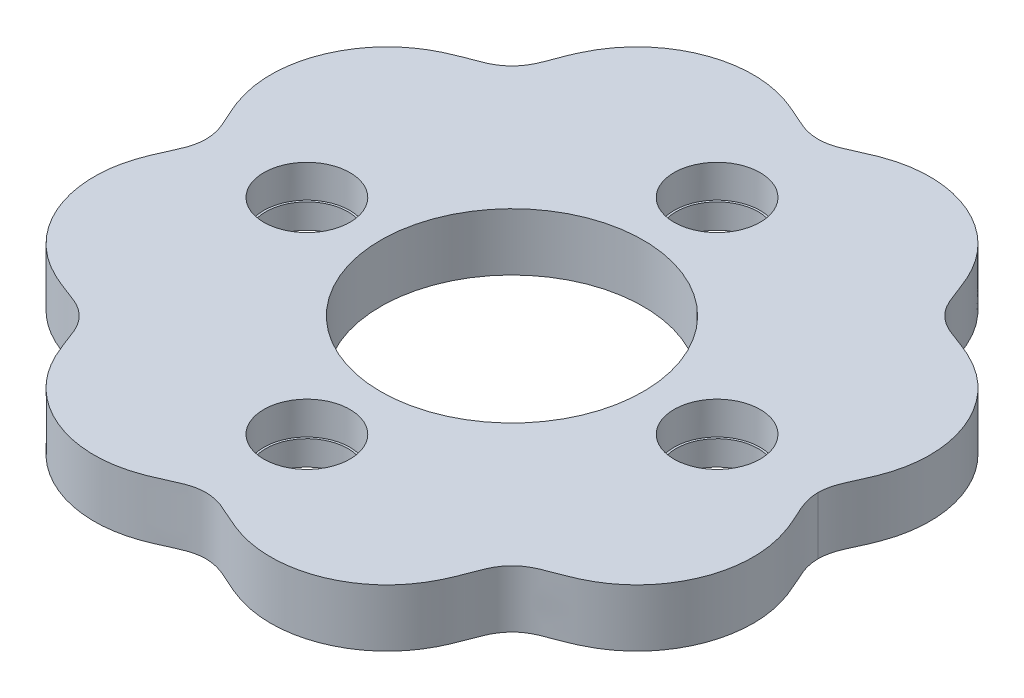
from build123d import *

# Parameters (mm, degrees)
BOSS_EXTRUDE1_DEPTH = 7
SKETCH3_R           = 16
SKETCH3_R_2         = 5.25
CUT_EXTRUDE1_DEPTH  = 7
CUT_EXTRUDE2_DEPTH  = 7
SKETCH5_R           = 5.25
SKETCH5_R_2         = 5
BOSS_EXTRUDE2_DEPTH = 3


with BuildPart() as part:
    # Sketch2 → Boss-Extrude1 (new body)
    with BuildSketch(Plane(origin=(0, 0, 0), x_dir=(1, 0, 0), z_dir=(0, 1, 0))):
        with BuildLine():
            add(Edge.make_bspline(
                [(37.500000178, 0), (37.500001348, -0.153650042), (37.516723117, -0.585734713), (37.60134551, -1.155885936), (37.799451038, -1.845132779), (38.055257689, -2.50061582), (38.284413658, -3.01884437), (38.547573645, -3.586057627), (38.834335204, -4.207231283), (39.213023964, -5.071386775), (39.642902809, -6.195484546), (40.034770345, -7.545626157), (40.309114863, -9.129071904), (40.402480997, -10.733442687), (40.292330227, -12.739242447), (39.800709206, -15.115411572), (38.875008006, -17.372282299), (37.550500891, -19.416826213), (36.201869244, -20.937061223), (34.991297456, -22.022332107), (33.664442598, -22.961820777), (32.418877976, -23.648429526), (31.307176029, -24.144813461), (30.415442254, -24.492540623), (29.760772524, -24.733252947), (29.159260868, -24.953726937), (28.615153012, -25.166050116), (27.968227921, -25.455751973), (27.242450172, -25.869161743), (26.486758972, -26.478530797), (25.788934233, -27.338578085), (25.333439826, -28.199550113), (25.02084924, -28.978917238), (24.756184284, -29.69717513), (24.520071708, -30.342148991), (24.176798097, -31.229963234), (23.685673389, -32.343953643), (23.006023391, -33.593318677), (22.074382722, -34.925670234), (20.99628636, -36.142619362), (19.483992231, -37.500137581), (17.436434568, -38.843473511), (15.165772212, -39.787003781), (12.765640508, -40.290729235), (10.727941267, -40.403684264), (9.098120231, -40.306732746), (7.490297544, -40.023060283), (6.12050869, -39.618509318), (4.980859334, -39.175936442), (3.981084292, -38.733166074), (3.107747272, -38.323212218), (2.16284156, -37.896233325), (1.102684883, -37.568652762), (-4e-09, -37.451718585), (-1.102684874, -37.568652759), (-2.162841573, -37.896233332), (-3.107747248, -38.323212203), (-3.981084328, -38.733166098), (-4.980859269, -39.175936398), (-6.120508811, -39.6185094), (-7.490297349, -40.023060149), (-9.098120503, -40.306732933), (-10.727940878, -40.403683996), (-12.765641194, -40.290729708), (-15.165770912, -39.787002885), (-17.436436591, -38.843474905), (-19.48398961, -37.500135775), (-20.996290415, -36.142622155), (-22.074374394, -34.925664496), (-23.006039129, -33.59332952), (-23.685647307, -32.343935674), (-24.176838549, -31.229991103), (-24.570729586, -30.210893235), (-24.899588849, -29.300399238), (-25.267416458, -28.324512461), (-25.788900803, -27.338555053), (-26.486780724, -26.478545782), (-27.242436428, -25.869152274), (-27.968236735, -25.455758045), (-28.615147496, -25.166046316), (-29.159264206, -24.953729236), (-29.760770668, -24.733251668), (-30.415443148, -24.492541238), (-31.307175489, -24.144813089), (-32.41887831, -23.648429756), (-33.6644424, -22.96182064), (-34.99129756, -22.022332179), (-36.201869193, -20.937061188), (-37.550500924, -19.416826235), (-38.875007981, -17.372282282), (-39.800709222, -15.115411584), (-40.292330218, -12.739242441), (-40.402481002, -10.733442691), (-40.309114859, -9.129071901), (-40.034770347, -7.545626159), (-39.642902807, -6.195484545), (-39.213023965, -5.071386776), (-38.834335204, -4.207231283), (-38.547573646, -3.586057627), (-38.284413658, -3.01884437), (-38.055257689, -2.50061582), (-37.799451038, -1.845132779), (-37.60134551, -1.155885936), (-37.516723117, -0.585734713), (-37.500001348, -0.153650042), (-37.500000178, 0)],
                knots=[0.119900748, 0.119900748, 0.119900748, 0.119900748, 0.119900748, 0.123359436, 0.129627259, 0.132815238, 0.136003217, 0.139191195, 0.142379174, 0.14689104, 0.151402906, 0.160426638, 0.169450869, 0.1784751, 0.187499512, 0.196523925, 0.214572937, 0.232831382, 0.241960244, 0.251089107, 0.260218415, 0.269347723, 0.278476117, 0.283040314, 0.287604511, 0.290890352, 0.294176194, 0.297462035, 0.300747877, 0.306837966, 0.312927068, 0.319161334, 0.325493528, 0.328659626, 0.331825723, 0.336390118, 0.340954513, 0.350083302, 0.35921236, 0.368341418, 0.377470301, 0.386599184, 0.404857643, 0.423193135, 0.432360527, 0.441527919, 0.450695565, 0.459863212, 0.469030281, 0.473613816, 0.47819735, 0.484472892, 0.490748434, 0.496943117, 0.503056883, 0.509251566, 0.515527108, 0.52180265, 0.526386184, 0.530969719, 0.540136788, 0.549304435, 0.558472081, 0.567639473, 0.576806865, 0.595142357, 0.613400816, 0.622529699, 0.631658582, 0.64078764, 0.649916698, 0.659045487, 0.663609882, 0.668174277, 0.674506472, 0.680838666, 0.687072932, 0.693162034, 0.699252123, 0.702537965, 0.705823806, 0.709109648, 0.712395489, 0.716959686, 0.721523883, 0.730652277, 0.739781585, 0.748910893, 0.758039756, 0.767168618, 0.785427063, 0.803476075, 0.812500488, 0.8215249, 0.830549131, 0.839573362, 0.848597094, 0.85310896, 0.857620826, 0.860808805, 0.863996783, 0.867184762, 0.870372741, 0.876640564, 0.880099252, 0.880099252, 0.880099252, 0.880099252, 0.880099252], degree=4))
            add(Edge.make_bspline(
                [(37.500000178, 0), (37.500001348, 0.153650042), (37.516723117, 0.585734713), (37.60134551, 1.155885936), (37.799451038, 1.845132779), (38.055257689, 2.50061582), (38.284413658, 3.018844371), (38.547573645, 3.586057627), (38.834335204, 4.207231284), (39.213023964, 5.071386775), (39.642902809, 6.195484546), (40.034770345, 7.545626157), (40.309114863, 9.129071904), (40.402480997, 10.733442688), (40.292330227, 12.739242447), (39.800709205, 15.115411572), (38.875008006, 17.3722823), (37.550500891, 19.416826213), (36.201869244, 20.937061223), (34.991297456, 22.022332107), (33.664442598, 22.961820777), (32.418877976, 23.648429526), (31.307176029, 24.144813461), (30.415442254, 24.492540623), (29.760772524, 24.733252947), (29.159260868, 24.953726937), (28.615153012, 25.166050117), (27.968227921, 25.455751974), (27.242450172, 25.869161744), (26.486758972, 26.478530797), (25.788934233, 27.338578085), (25.333439826, 28.199550113), (25.02084924, 28.978917238), (24.756184284, 29.69717513), (24.520071708, 30.342148991), (24.176798097, 31.229963234), (23.685673389, 32.343953643), (23.006023391, 33.593318677), (22.074382722, 34.925670234), (20.99628636, 36.142619362), (19.483992231, 37.500137582), (17.436434568, 38.843473511), (15.165772212, 39.787003781), (12.765640508, 40.290729235), (10.727941267, 40.403684265), (9.098120231, 40.306732746), (7.490297544, 40.023060283), (6.12050869, 39.618509318), (4.980859334, 39.175936443), (3.981084292, 38.733166074), (3.107747271, 38.323212218), (2.162841559, 37.896233325), (1.102684882, 37.568652762), (-4e-09, 37.451718586), (-1.102684874, 37.568652759), (-2.162841573, 37.896233332), (-3.107747248, 38.323212203), (-3.981084328, 38.733166098), (-4.980859269, 39.175936399), (-6.120508811, 39.6185094), (-7.490297349, 40.023060149), (-9.098120503, 40.306732933), (-10.727940878, 40.403683996), (-12.765641194, 40.290729708), (-15.165770912, 39.787002885), (-17.436436591, 38.843474905), (-19.48398961, 37.500135776), (-20.996290415, 36.142622155), (-22.074374394, 34.925664496), (-23.006039129, 33.59332952), (-23.685647307, 32.343935674), (-24.176838549, 31.229991103), (-24.570729586, 30.210893235), (-24.899588849, 29.300399238), (-25.267416458, 28.324512461), (-25.788900803, 27.338555053), (-26.486780724, 26.478545782), (-27.242436428, 25.869152274), (-27.968236735, 25.455758045), (-28.615147496, 25.166046316), (-29.159264206, 24.953729236), (-29.760770668, 24.733251668), (-30.415443148, 24.492541238), (-31.307175489, 24.144813089), (-32.418878311, 23.648429756), (-33.6644424, 22.96182064), (-34.99129756, 22.022332179), (-36.201869193, 20.937061188), (-37.550500924, 19.416826235), (-38.875007981, 17.372282282), (-39.800709222, 15.115411584), (-40.292330218, 12.739242441), (-40.402481002, 10.733442691), (-40.309114859, 9.129071901), (-40.034770347, 7.545626159), (-39.642902807, 6.195484545), (-39.213023965, 5.071386776), (-38.834335204, 4.207231283), (-38.547573646, 3.586057627), (-38.284413658, 3.01884437), (-38.055257689, 2.50061582), (-37.799451038, 1.845132779), (-37.60134551, 1.155885936), (-37.516723117, 0.585734713), (-37.500001348, 0.153650042), (-37.500000178, 0)],
                knots=[0.119900748, 0.119900748, 0.119900748, 0.119900748, 0.119900748, 0.123359436, 0.129627259, 0.132815238, 0.136003217, 0.139191195, 0.142379174, 0.14689104, 0.151402906, 0.160426638, 0.169450869, 0.1784751, 0.187499512, 0.196523925, 0.214572937, 0.232831382, 0.241960244, 0.251089107, 0.260218415, 0.269347723, 0.278476117, 0.283040314, 0.287604511, 0.290890352, 0.294176194, 0.297462035, 0.300747877, 0.306837966, 0.312927068, 0.319161334, 0.325493528, 0.328659626, 0.331825723, 0.336390118, 0.340954513, 0.350083302, 0.35921236, 0.368341418, 0.377470301, 0.386599184, 0.404857643, 0.423193135, 0.432360527, 0.441527919, 0.450695565, 0.459863212, 0.469030281, 0.473613816, 0.47819735, 0.484472892, 0.490748434, 0.496943117, 0.503056883, 0.509251566, 0.515527108, 0.52180265, 0.526386184, 0.530969719, 0.540136788, 0.549304435, 0.558472081, 0.567639473, 0.576806865, 0.595142357, 0.613400816, 0.622529699, 0.631658582, 0.64078764, 0.649916698, 0.659045487, 0.663609882, 0.668174277, 0.674506472, 0.680838666, 0.687072932, 0.693162034, 0.699252123, 0.702537965, 0.705823806, 0.709109648, 0.712395489, 0.716959686, 0.721523883, 0.730652277, 0.739781585, 0.748910893, 0.758039756, 0.767168618, 0.785427063, 0.803476075, 0.812500488, 0.8215249, 0.830549131, 0.839573362, 0.848597094, 0.85310896, 0.857620826, 0.860808805, 0.863996783, 0.867184762, 0.870372741, 0.876640564, 0.880099252, 0.880099252, 0.880099252, 0.880099252, 0.880099252], degree=4))
        make_face()
    extrude(amount=BOSS_EXTRUDE1_DEPTH)

    # Sketch3 → Cut-Extrude1 (cut)
    with BuildSketch(Plane(origin=(0, 7, 0), x_dir=(1, 0, 0), z_dir=(0, 1, 0))):
        with Locations(Location((0, 0, 0), (0, 0, 270))):
            Circle(SKETCH3_R)
        with Locations(Location((25, 0, 0), (0, 0, 270))):
            Circle(SKETCH3_R_2)
        with Locations(Location((0, -25, 0), (0, 0, 270))):
            Circle(SKETCH3_R_2)
        with Locations(Location((-25, 0, 0), (0, 0, 270))):
            Circle(SKETCH3_R_2)
        with Locations(Location((0, 25, 0), (0, 0, 270))):
            Circle(SKETCH3_R_2)
    extrude(amount=-CUT_EXTRUDE1_DEPTH, mode=Mode.SUBTRACT)

    # Sketch4 → Cut-Extrude2 (cut)
    with BuildSketch(Plane.XZ):
        with BuildLine():
            add(Edge.make_bspline(
                [(37.500000178, 0), (37.500001348, 0.153650042), (37.516723117, 0.585734713), (37.60134551, 1.155885936), (37.799451038, 1.845132779), (38.055257689, 2.50061582), (38.284413658, 3.01884437), (38.547573645, 3.586057627), (38.834335204, 4.207231283), (39.213023964, 5.071386775), (39.642902809, 6.195484546), (40.034770345, 7.545626157), (40.309114863, 9.129071904), (40.402480997, 10.733442687), (40.292330227, 12.739242447), (39.800709206, 15.115411572), (38.875008006, 17.372282299), (37.550500891, 19.416826213), (36.201869244, 20.937061223), (34.991297456, 22.022332107), (33.664442598, 22.961820777), (32.418877976, 23.648429526), (31.307176029, 24.144813461), (30.415442254, 24.492540623), (29.760772524, 24.733252947), (29.159260868, 24.953726937), (28.615153012, 25.166050116), (27.968227921, 25.455751973), (27.242450172, 25.869161743), (26.486758972, 26.478530797), (25.788934233, 27.338578085), (25.333439826, 28.199550113), (25.02084924, 28.978917238), (24.756184284, 29.69717513), (24.520071708, 30.342148991), (24.176798097, 31.229963234), (23.685673389, 32.343953643), (23.006023391, 33.593318677), (22.074382722, 34.925670234), (20.99628636, 36.142619362), (19.483992231, 37.500137581), (17.436434568, 38.843473511), (15.165772212, 39.787003781), (12.765640508, 40.290729235), (10.727941267, 40.403684264), (9.098120231, 40.306732746), (7.490297544, 40.023060283), (6.12050869, 39.618509318), (4.980859334, 39.175936442), (3.981084292, 38.733166074), (3.107747272, 38.323212218), (2.16284156, 37.896233325), (1.102684883, 37.568652762), (-4e-09, 37.451718585), (-1.102684874, 37.568652759), (-2.162841573, 37.896233332), (-3.107747248, 38.323212203), (-3.981084328, 38.733166098), (-4.980859269, 39.175936398), (-6.120508811, 39.6185094), (-7.490297349, 40.023060149), (-9.098120503, 40.306732933), (-10.727940878, 40.403683996), (-12.765641194, 40.290729708), (-15.165770912, 39.787002885), (-17.436436591, 38.843474905), (-19.48398961, 37.500135775), (-20.996290415, 36.142622155), (-22.074374394, 34.925664496), (-23.006039129, 33.59332952), (-23.685647307, 32.343935674), (-24.176838549, 31.229991103), (-24.570729586, 30.210893235), (-24.899588849, 29.300399238), (-25.267416458, 28.324512461), (-25.788900803, 27.338555053), (-26.486780724, 26.478545782), (-27.242436428, 25.869152274), (-27.968236735, 25.455758045), (-28.615147496, 25.166046316), (-29.159264206, 24.953729236), (-29.760770668, 24.733251668), (-30.415443148, 24.492541238), (-31.307175489, 24.144813089), (-32.41887831, 23.648429756), (-33.6644424, 22.96182064), (-34.99129756, 22.022332179), (-36.201869193, 20.937061188), (-37.550500924, 19.416826235), (-38.875007981, 17.372282282), (-39.800709222, 15.115411584), (-40.292330218, 12.739242441), (-40.402481002, 10.733442691), (-40.309114859, 9.129071901), (-40.034770347, 7.545626159), (-39.642902807, 6.195484545), (-39.213023965, 5.071386776), (-38.834335204, 4.207231283), (-38.547573646, 3.586057627), (-38.284413658, 3.01884437), (-38.055257689, 2.50061582), (-37.799451038, 1.845132779), (-37.60134551, 1.155885936), (-37.516723117, 0.585734713), (-37.500001348, 0.153650042), (-37.500000178, 0)],
                knots=[0.119900748, 0.119900748, 0.119900748, 0.119900748, 0.119900748, 0.123359436, 0.129627259, 0.132815238, 0.136003217, 0.139191195, 0.142379174, 0.14689104, 0.151402906, 0.160426638, 0.169450869, 0.1784751, 0.187499512, 0.196523925, 0.214572937, 0.232831382, 0.241960244, 0.251089107, 0.260218415, 0.269347723, 0.278476117, 0.283040314, 0.287604511, 0.290890352, 0.294176194, 0.297462035, 0.300747877, 0.306837966, 0.312927068, 0.319161334, 0.325493528, 0.328659626, 0.331825723, 0.336390118, 0.340954513, 0.350083302, 0.35921236, 0.368341418, 0.377470301, 0.386599184, 0.404857643, 0.423193135, 0.432360527, 0.441527919, 0.450695565, 0.459863212, 0.469030281, 0.473613816, 0.47819735, 0.484472892, 0.490748434, 0.496943117, 0.503056883, 0.509251566, 0.515527108, 0.52180265, 0.526386184, 0.530969719, 0.540136788, 0.549304435, 0.558472081, 0.567639473, 0.576806865, 0.595142357, 0.613400816, 0.622529699, 0.631658582, 0.64078764, 0.649916698, 0.659045487, 0.663609882, 0.668174277, 0.674506472, 0.680838666, 0.687072932, 0.693162034, 0.699252123, 0.702537965, 0.705823806, 0.709109648, 0.712395489, 0.716959686, 0.721523883, 0.730652277, 0.739781585, 0.748910893, 0.758039756, 0.767168618, 0.785427063, 0.803476075, 0.812500488, 0.8215249, 0.830549131, 0.839573362, 0.848597094, 0.85310896, 0.857620826, 0.860808805, 0.863996783, 0.867184762, 0.870372741, 0.876640564, 0.880099252, 0.880099252, 0.880099252, 0.880099252, 0.880099252], degree=4))
            add(Edge.make_bspline(
                [(-37.500000178, 0), (-37.500001348, -0.153650042), (-37.516723117, -0.585734713), (-37.60134551, -1.155885936), (-37.799451038, -1.845132779), (-38.055257689, -2.50061582), (-38.284413658, -3.01884437), (-38.547573646, -3.586057627), (-38.834335204, -4.207231283), (-39.213023965, -5.071386776), (-39.642902807, -6.195484545), (-40.034770347, -7.545626159), (-40.309114859, -9.129071901), (-40.402481002, -10.733442691), (-40.292330218, -12.739242441), (-39.800709222, -15.115411584), (-38.875007981, -17.372282282), (-37.550500924, -19.416826235), (-36.201869193, -20.937061188), (-34.99129756, -22.022332179), (-33.6644424, -22.96182064), (-32.418878311, -23.648429756), (-31.307175489, -24.144813089), (-30.415443148, -24.492541238), (-29.760770668, -24.733251668), (-29.159264206, -24.953729236), (-28.615147496, -25.166046316), (-27.968236735, -25.455758045), (-27.242436428, -25.869152274), (-26.486780724, -26.478545782), (-25.788900803, -27.338555053), (-25.267416458, -28.324512461), (-24.899588849, -29.300399238), (-24.570729586, -30.210893235), (-24.176838549, -31.229991103), (-23.685647307, -32.343935674), (-23.006039129, -33.59332952), (-22.074374394, -34.925664496), (-20.996290415, -36.142622155), (-19.48398961, -37.500135776), (-17.436436591, -38.843474905), (-15.165770912, -39.787002885), (-12.765641194, -40.290729708), (-10.727940878, -40.403683996), (-9.098120503, -40.306732933), (-7.490297349, -40.023060149), (-6.120508811, -39.6185094), (-4.980859269, -39.175936399), (-3.981084328, -38.733166098), (-3.107747248, -38.323212203), (-2.162841573, -37.896233332), (-1.102684874, -37.568652759), (-4e-09, -37.451718586), (1.102684882, -37.568652762), (2.162841559, -37.896233325), (3.107747271, -38.323212218), (3.981084292, -38.733166074), (4.980859334, -39.175936443), (6.12050869, -39.618509318), (7.490297544, -40.023060283), (9.098120231, -40.306732746), (10.727941267, -40.403684265), (12.765640508, -40.290729235), (15.165772212, -39.787003781), (17.436434568, -38.843473511), (19.483992231, -37.500137582), (20.99628636, -36.142619362), (22.074382722, -34.925670234), (23.006023391, -33.593318677), (23.685673389, -32.343953643), (24.176798097, -31.229963234), (24.520071708, -30.342148991), (24.756184284, -29.69717513), (25.02084924, -28.978917238), (25.333439826, -28.199550113), (25.788934233, -27.338578085), (26.486758972, -26.478530797), (27.242450172, -25.869161744), (27.968227921, -25.455751974), (28.615153012, -25.166050117), (29.159260868, -24.953726937), (29.760772524, -24.733252947), (30.415442254, -24.492540623), (31.307176029, -24.144813461), (32.418877976, -23.648429526), (33.664442598, -22.961820777), (34.991297456, -22.022332107), (36.201869244, -20.937061223), (37.550500891, -19.416826213), (38.875008006, -17.3722823), (39.800709205, -15.115411572), (40.292330227, -12.739242447), (40.402480997, -10.733442688), (40.309114863, -9.129071904), (40.034770345, -7.545626157), (39.642902809, -6.195484546), (39.213023964, -5.071386775), (38.834335204, -4.207231284), (38.547573645, -3.586057627), (38.284413658, -3.018844371), (38.055257689, -2.50061582), (37.799451038, -1.845132779), (37.60134551, -1.155885936), (37.516723117, -0.585734713), (37.500001348, -0.153650042), (37.500000178, 0)],
                knots=[0.119900748, 0.119900748, 0.119900748, 0.119900748, 0.119900748, 0.123359436, 0.129627259, 0.132815238, 0.136003217, 0.139191195, 0.142379174, 0.14689104, 0.151402906, 0.160426638, 0.169450869, 0.1784751, 0.187499512, 0.196523925, 0.214572937, 0.232831382, 0.241960244, 0.251089107, 0.260218415, 0.269347723, 0.278476117, 0.283040314, 0.287604511, 0.290890352, 0.294176194, 0.297462035, 0.300747877, 0.306837966, 0.312927068, 0.319161334, 0.325493528, 0.331825723, 0.336390118, 0.340954513, 0.350083302, 0.35921236, 0.368341418, 0.377470301, 0.386599184, 0.404857643, 0.423193135, 0.432360527, 0.441527919, 0.450695565, 0.459863212, 0.469030281, 0.473613816, 0.47819735, 0.484472892, 0.490748434, 0.496943117, 0.503056883, 0.509251566, 0.515527108, 0.52180265, 0.526386184, 0.530969719, 0.540136788, 0.549304435, 0.558472081, 0.567639473, 0.576806865, 0.595142357, 0.613400816, 0.622529699, 0.631658582, 0.64078764, 0.649916698, 0.659045487, 0.663609882, 0.668174277, 0.671340374, 0.674506472, 0.680838666, 0.687072932, 0.693162034, 0.699252123, 0.702537965, 0.705823806, 0.709109648, 0.712395489, 0.716959686, 0.721523883, 0.730652277, 0.739781585, 0.748910893, 0.758039756, 0.767168618, 0.785427063, 0.803476075, 0.812500488, 0.8215249, 0.830549131, 0.839573362, 0.848597094, 0.85310896, 0.857620826, 0.860808805, 0.863996783, 0.867184762, 0.870372741, 0.876640564, 0.880099252, 0.880099252, 0.880099252, 0.880099252, 0.880099252], degree=4))
        make_face()
        with BuildLine():
            add(Edge.make_bspline(
                [(-37.300000178, -1.524e-06), (-37.300005335, -0.676867371), (-37.427636497, -1.325473476), (-37.853250651, -2.584965326), (-38.147131523, -3.195245044), (-38.710737195, -4.418667543), (-38.982798601, -5.033561115), (-39.450771862, -6.288224734), (-39.648035819, -6.927553077), (-39.875673706, -7.908844077), (-39.940344955, -8.239602513), (-40.046090854, -8.908827903), (-40.087286369, -9.248679407), (-40.172949866, -10.27022305), (-40.179625206, -10.947626333), (-40.096430658, -12.295492001), (-40.006581856, -12.965955902), (-39.798317767, -13.966368295), (-39.716248424, -14.299914705), (-39.529875703, -14.955124894), (-39.425421525, -15.277863119), (-39.07900274, -16.231799922), (-38.804163449, -16.848799053), (-38.166153555, -18.044644678), (-37.799492988, -18.627625556), (-36.995130035, -19.722329216), (-36.55702023, -20.236493497), (-35.609382413, -21.198851965), (-35.098848237, -21.647731332), (-34.006848553, -22.473314445), (-33.436641819, -22.841333302), (-32.252551038, -23.49658613), (-31.638105387, -23.782781365), (-30.693579545, -24.169797582), (-30.374923098, -24.29196642), (-29.735334328, -24.530156066), (-29.414121244, -24.64587707), (-28.776119551, -24.887840957), (-28.459558035, -25.014623888), (-27.841899581, -25.30496618), (-27.538474652, -25.470402701), (-26.968530323, -25.84818003), (-26.70266287, -26.059307537), (-26.212204012, -26.529609939), (-25.985689891, -26.791762949), (-25.586463853, -27.347680771), (-25.41329678, -27.640928729), (-25.106118272, -28.250061479), (-24.972145407, -28.566214123), (-24.721951409, -29.207052359), (-24.604673392, -29.531396076), (-24.365978823, -30.178006246), (-24.244860769, -30.500422525), (-23.861965565, -31.457863081), (-23.579994139, -32.082751199), (-22.93073246, -33.289703159), (-22.564564445, -33.872330289), (-21.944749407, -34.710853127), (-21.725410999, -34.985571353), (-21.270313026, -35.513530833), (-21.034058454, -35.767647044), (-20.299828428, -36.501142055), (-19.77651621, -36.951814008), (-18.662658422, -37.776981752), (-18.067184766, -38.153631121), (-16.84205779, -38.808251323), (-16.210381542, -39.088693428), (-15.234619198, -39.440087375), (-14.904636476, -39.545623277), (-14.235030876, -39.733055651), (-13.893995034, -39.815213549), (-12.183094407, -40.161008791), (-10.804309777, -40.234150035), (-9.068024089, -40.066663686), (-8.719971551, -40.019815553), (-8.033988167, -39.901414802), (-7.694604804, -39.829735338), (-6.686761662, -39.579051281), (-6.02890771, -39.363367369), (-4.734913886, -38.856903314), (-4.09967909, -38.563862442), (-2.831226885, -37.978648162), (-2.195461735, -37.68983752), (-1.177345947, -37.415650241), (-0.830881373, -37.351821484), (-0.138817065, -37.29091559), (0.20907518, -37.292911809), (0.908697102, -37.363847996), (1.254123511, -37.432795894), (1.923534855, -37.620991628), (2.250175655, -37.740536869), (2.894567623, -38.007677129), (3.212569296, -38.154445485), (3.848679122, -38.448235746), (4.166662192, -38.595380732), (5.126011798, -39.018034516), (5.77299927, -39.273995175), (7.093462946, -39.693795626), (7.766556663, -39.858965602), (8.79794485, -40.031088074), (9.145338463, -40.075950894), (9.84763557, -40.139559133), (10.204439892, -40.158296893), (11.981061205, -40.183352107), (13.374101934, -39.99116426), (15.0807472, -39.4906324), (15.418995639, -39.377488677), (16.081101817, -39.128399482), (16.406210156, -38.992100462), (17.363980082, -38.548492104), (17.97919541, -38.206686663), (18.866236672, -37.623228073), (19.157096225, -37.415961043), (19.7199732, -36.981810571), (19.991631279, -36.755377595), (20.777834873, -36.048551371), (21.26373655, -35.540752153), (21.934837883, -34.723797907), (22.148877277, -34.442236285), (22.557321054, -33.860326574), (22.751308058, -33.560329192), (23.296633068, -32.645197526), (23.613079431, -32.01037547), (24.035024821, -31.030456758), (24.167085908, -30.699362692), (24.42071489, -30.03357086), (24.542165455, -29.698502186), (24.789943229, -29.030340214), (24.916288451, -28.697254212), (25.203031469, -28.04487583), (25.365328746, -27.723501519), (25.738863592, -27.118626541), (25.949588891, -26.83484909), (26.425345949, -26.30959178), (26.693427061, -26.066305249), (27.262376931, -25.640526196), (27.56458752, -25.45587752), (28.196201984, -25.129880607), (28.525768024, -24.988616885), (29.195057198, -24.725991917), (29.534624796, -24.603555748), (30.211020774, -24.35374453), (30.54805671, -24.22674371), (31.547163494, -23.824103094), (32.196759504, -23.525970845), (33.44512828, -22.83807073), (34.04463883, -22.449633109), (34.902881218, -21.793010366), (35.18215621, -21.561865079), (35.726440643, -21.073853349), (35.992909512, -20.815365155), (36.754934237, -20.015059637), (37.215569576, -19.447621742), (38.045919188, -18.247692555), (38.41581225, -17.614905719), (39.060809726, -16.283216984), (39.327825486, -15.601135481), (39.755290796, -14.205785793), (39.915743077, -13.492518407), (40.073287437, -12.398288082), (40.111713427, -12.029358579), (40.159120983, -11.296377239), (40.168380307, -10.930685523), (40.153413888, -9.835974665), (40.086539323, -9.109314524), (39.899940664, -8.024097027), (39.822944519, -7.661850311), (39.641972096, -6.946076066), (39.53821078, -6.592991809), (39.19106012, -5.546715434), (38.9097543, -4.867241305), (38.454863731, -3.859944684), (38.297872988, -3.526119045), (37.992404669, -2.855385887), (37.844569648, -2.518245277), (37.590630842, -1.828852716), (37.484865024, -1.476478384), (37.339064604, -0.747927725), (37.300003029, -0.374141758), (37.300000178, -1.524e-06)],
                knots=[0, 0, 0, 0, 0.015625, 0.015625, 0.03125, 0.03125, 0.046875, 0.046875, 0.0625, 0.0625, 0.0703125, 0.0703125, 0.078125, 0.078125, 0.09375, 0.09375, 0.109375, 0.109375, 0.1171875, 0.1171875, 0.125, 0.125, 0.140625, 0.140625, 0.15625, 0.15625, 0.171875, 0.171875, 0.1875, 0.1875, 0.203125, 0.203125, 0.21875, 0.21875, 0.2265625, 0.2265625, 0.234375, 0.234375, 0.2421875, 0.2421875, 0.25, 0.25, 0.2578125, 0.2578125, 0.265625, 0.265625, 0.2734375, 0.2734375, 0.28125, 0.28125, 0.2890625, 0.2890625, 0.296875, 0.296875, 0.3125, 0.3125, 0.328125, 0.328125, 0.3359375, 0.3359375, 0.34375, 0.34375, 0.359375, 0.359375, 0.375, 0.375, 0.390625, 0.390625, 0.3984375, 0.3984375, 0.40625, 0.40625, 0.4375, 0.4375, 0.4453125, 0.4453125, 0.453125, 0.453125, 0.46875, 0.46875, 0.484375, 0.484375, 0.5, 0.5, 0.5078125, 0.5078125, 0.515625, 0.515625, 0.5234375, 0.5234375, 0.53125, 0.53125, 0.5390625, 0.5390625, 0.546875, 0.546875, 0.5625, 0.5625, 0.578125, 0.578125, 0.5859375, 0.5859375, 0.59375, 0.59375, 0.625, 0.625, 0.6328125, 0.6328125, 0.640625, 0.640625, 0.65625, 0.65625, 0.6640625, 0.6640625, 0.671875, 0.671875, 0.6875, 0.6875, 0.6953125, 0.6953125, 0.703125, 0.703125, 0.71875, 0.71875, 0.7265625, 0.7265625, 0.734375, 0.734375, 0.7421875, 0.7421875, 0.75, 0.75, 0.7578125, 0.7578125, 0.765625, 0.765625, 0.7734375, 0.7734375, 0.78125, 0.78125, 0.7890625, 0.7890625, 0.796875, 0.796875, 0.8125, 0.8125, 0.828125, 0.828125, 0.8359375, 0.8359375, 0.84375, 0.84375, 0.859375, 0.859375, 0.875, 0.875, 0.890625, 0.890625, 0.90625, 0.90625, 0.9140625, 0.9140625, 0.921875, 0.921875, 0.9375, 0.9375, 0.9453125, 0.9453125, 0.953125, 0.953125, 0.96875, 0.96875, 0.9765625, 0.9765625, 0.984375, 0.984375, 0.9921875, 0.9921875, 1, 1, 1, 1], degree=3))
            add(Edge.make_bspline(
                [(37.300000178, -1.524e-06), (37.300005208, 0.660144226), (37.421411779, 1.295517379), (37.831734078, 2.532082599), (38.116935876, 3.130913102), (38.66996567, 4.329106329), (38.939096345, 4.930571557), (39.405964802, 6.156402501), (39.605047777, 6.780336723), (39.916633728, 8.055977178), (40.029822796, 8.707463335), (40.129263615, 9.707256218), (40.150476293, 10.043512099), (40.168603216, 10.710754532), (40.16569842, 11.043295862), (40.121853762, 12.037750073), (40.04596153, 12.696509229), (39.800930827, 14.005614003), (39.629929243, 14.660025043), (39.203319809, 15.922840902), (38.947607438, 16.534995728), (38.352443795, 17.721287864), (38.01164261, 18.297386991), (36.865619793, 19.953006208), (35.965077358, 20.925749976), (34.668200294, 21.977408574), (34.399137664, 22.180045191), (33.849124311, 22.564175613), (33.568194294, 22.745768199), (32.708435952, 23.26054556), (32.112158136, 23.562879166), (30.883355545, 24.103460776), (30.253463108, 24.33873727), (28.992284812, 24.802673436), (28.359269177, 25.033693876), (27.173041908, 25.672514094), (26.640421314, 26.071830768), (25.732243211, 27.075117404), (25.3881266, 27.646349548), (24.970450113, 28.565526018), (24.847078992, 28.880994442), (24.608670909, 29.516260023), (24.493248755, 29.835986238), (24.136201537, 30.789197307), (23.882826599, 31.416178136), (23.0112342, 33.235418868), (22.282526036, 34.366517759), (21.14183152, 35.65318275), (20.900908683, 35.905544246), (20.402861765, 36.389571629), (20.146235185, 36.621002802), (19.354227833, 37.284497662), (18.796838061, 37.685927789), (17.917194752, 38.227445206), (17.616690295, 38.397804286), (17.000801173, 38.717811199), (16.685302872, 38.867360076), (15.731897553, 39.277610568), (15.082085717, 39.502910242), (13.754543594, 39.858798155), (13.076303966, 39.989464784), (11.692472346, 40.150698781), (11.003326073, 40.179384795), (9.630398499, 40.136159356), (8.946624716, 40.064106935), (7.925054091, 39.879336655), (7.584068392, 39.804584904), (6.911102375, 39.631582084), (6.578787823, 39.533352223), (5.593179411, 39.206769583), (4.951763876, 38.944995717), (4.001222146, 38.519748784), (3.686215525, 38.37274594), (3.054939486, 38.082334811), (2.738671787, 37.939003624), (1.774376643, 37.555125527), (1.108416265, 37.365702832), (-0.313242705, 37.26305357), (-1.009819495, 37.353721127), (-2.373134662, 37.759482708), (-3.020435969, 38.065714366), (-4.31922425, 38.665586321), (-4.970996576, 38.958368217), (-6.303290418, 39.457448435), (-6.983156607, 39.665718112), (-8.028742238, 39.900551902), (-8.38150253, 39.966099849), (-9.095953619, 40.070330911), (-9.459164574, 40.109032745), (-10.542292685, 40.181785054), (-11.260648975, 40.173939549), (-12.690162629, 40.049472575), (-13.402303785, 39.93264955), (-14.815140156, 39.587636547), (-15.49961688, 39.363583018), (-16.826571564, 38.816808356), (-17.469046393, 38.49407987), (-18.400199275, 37.933495503), (-18.705278844, 37.733539312), (-19.293957386, 37.314680679), (-19.578928892, 37.095003085), (-20.406107655, 36.405627556), (-20.920721522, 35.905742621), (-21.636047699, 35.094001047), (-21.865738476, 34.812071146), (-22.30216479, 34.231468298), (-22.507864629, 33.934330063), (-23.089081297, 33.023310305), (-23.427950481, 32.389405873), (-24.026693363, 31.078436817), (-24.284665302, 30.399987851), (-24.785829721, 29.038501872), (-25.029748887, 28.354949713), (-25.555483159, 27.397017304), (-25.757179306, 27.090563947), (-26.210844694, 26.529370711), (-26.463914838, 26.271703557), (-27.024732982, 25.804153386), (-27.327595986, 25.59913821), (-27.958226263, 25.242998486), (-28.288028419, 25.090485933), (-28.962903163, 24.812754276), (-29.306820586, 24.686962968), (-29.994054984, 24.434168853), (-30.337434391, 24.307292012), (-31.357424955, 23.906187), (-32.023447973, 23.610595593), (-33.307440523, 22.922457321), (-33.926138193, 22.531379588), (-34.81427105, 21.864230931), (-35.10265734, 21.629071247), (-35.654941854, 21.141050975), (-35.920235243, 20.887187618), (-36.684231882, 20.096640102), (-37.151243071, 19.531172398), (-37.787653083, 18.624747418), (-37.989747764, 18.311551138), (-38.36606589, 17.675179304), (-38.540902679, 17.351335772), (-39.026418472, 16.363245214), (-39.298355219, 15.682545383), (-39.737624204, 14.276722964), (-39.904584783, 13.547861194), (-40.120046777, 12.093980332), (-40.170830834, 11.363377776), (-40.160755091, 10.261927286), (-40.14295873, 9.893848663), (-40.077625461, 9.155778871), (-40.030026871, 8.78681187), (-39.845507073, 7.696104416), (-39.665898802, 6.984547803), (-39.207134795, 5.588841869), (-38.92583868, 4.904518844), (-38.469054097, 3.890595764), (-38.311220852, 3.55473841), (-38.003352456, 2.88006077), (-37.853918969, 2.54101188), (-37.596472589, 1.847176107), (-37.488836022, 1.492246237), (-37.340112082, 0.757100749), (-37.300003062, 0.378477949), (-37.300000178, -1.524e-06)],
                knots=[0, 0, 0, 0, 0.015625, 0.015625, 0.03125, 0.03125, 0.046875, 0.046875, 0.0625, 0.0625, 0.078125, 0.078125, 0.0859375, 0.0859375, 0.09375, 0.09375, 0.109375, 0.109375, 0.125, 0.125, 0.140625, 0.140625, 0.15625, 0.15625, 0.1875, 0.1875, 0.1953125, 0.1953125, 0.203125, 0.203125, 0.21875, 0.21875, 0.234375, 0.234375, 0.25, 0.25, 0.265625, 0.265625, 0.28125, 0.28125, 0.2890625, 0.2890625, 0.296875, 0.296875, 0.3125, 0.3125, 0.34375, 0.34375, 0.3515625, 0.3515625, 0.359375, 0.359375, 0.375, 0.375, 0.3828125, 0.3828125, 0.390625, 0.390625, 0.40625, 0.40625, 0.421875, 0.421875, 0.4375, 0.4375, 0.453125, 0.453125, 0.4609375, 0.4609375, 0.46875, 0.46875, 0.484375, 0.484375, 0.4921875, 0.4921875, 0.5, 0.5, 0.515625, 0.515625, 0.53125, 0.53125, 0.546875, 0.546875, 0.5625, 0.5625, 0.578125, 0.578125, 0.5859375, 0.5859375, 0.59375, 0.59375, 0.609375, 0.609375, 0.625, 0.625, 0.640625, 0.640625, 0.65625, 0.65625, 0.6640625, 0.6640625, 0.671875, 0.671875, 0.6875, 0.6875, 0.6953125, 0.6953125, 0.703125, 0.703125, 0.71875, 0.71875, 0.734375, 0.734375, 0.75, 0.75, 0.7578125, 0.7578125, 0.765625, 0.765625, 0.7734375, 0.7734375, 0.78125, 0.78125, 0.7890625, 0.7890625, 0.796875, 0.796875, 0.8125, 0.8125, 0.828125, 0.828125, 0.8359375, 0.8359375, 0.84375, 0.84375, 0.859375, 0.859375, 0.8671875, 0.8671875, 0.875, 0.875, 0.890625, 0.890625, 0.90625, 0.90625, 0.921875, 0.921875, 0.9296875, 0.9296875, 0.9375, 0.9375, 0.953125, 0.953125, 0.96875, 0.96875, 0.9765625, 0.9765625, 0.984375, 0.984375, 0.9921875, 0.9921875, 1, 1, 1, 1], degree=3))
        make_face(mode=Mode.SUBTRACT)
    extrude(amount=-CUT_EXTRUDE2_DEPTH, mode=Mode.SUBTRACT)

    # Sketch5 → Boss-Extrude2 (add)
    with BuildSketch(Plane.XZ):
        with Locations(Location((0, 25, 0), (0, 0, 90))):
            Circle(SKETCH5_R)
        with Locations(Location((0, 25, 0), (0, 0, 270))):
            Circle(SKETCH5_R_2, mode=Mode.SUBTRACT)
        with Locations(Location((25, 0, 0), (0, 0, 90))):
            Circle(SKETCH5_R)
        with Locations(Location((25, 0, 0), (0, 0, 270))):
            Circle(SKETCH5_R_2, mode=Mode.SUBTRACT)
        with Locations(Location((-25, 0, 0), (0, 0, 90))):
            Circle(SKETCH5_R)
        with Locations(Location((-25, 0, 0), (0, 0, 270))):
            Circle(SKETCH5_R_2, mode=Mode.SUBTRACT)
        with Locations(Location((0, -25, 0), (0, 0, 90))):
            Circle(SKETCH5_R)
        with Locations(Location((0, -25, 0), (0, 0, 270))):
            Circle(SKETCH5_R_2, mode=Mode.SUBTRACT)
    extrude(amount=-BOSS_EXTRUDE2_DEPTH)


solid = part.part
